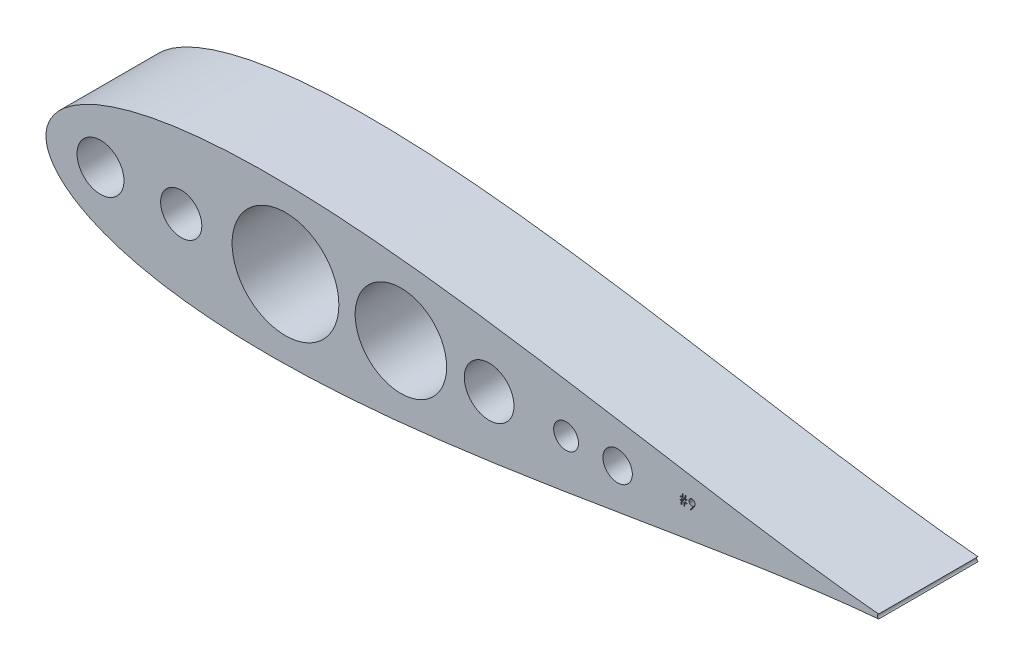
from build123d import *

# Parameters (mm, degrees)
SKETCH2_R           = 12.003328726
SKETCH2_R_2         = 10.541
SKETCH2_R_3         = 27.304154698
SKETCH2_R_4         = 12.7
SKETCH2_R_5         = 7.526838105
SKETCH2_R_6         = 23.387800821
SKETCH2_R_7         = 6.35
BOSS_EXTRUDE1_DEPTH = 50.8


with BuildPart() as part:
    # Sketch2 → Boss-Extrude1 (new body)
    with BuildSketch(Plane.XY):
        with BuildLine():
            ThreePointArc((356.718780851, 1.114246934), (356.028706076, 6.909e-06), (356.718780769, -1.114233167))
            add(Edge.make_bspline(
                [(356.718780851, 1.114246934), (356.033763733, 1.173178101), (354.647215992, 1.292458827), (352.543574548, 1.484422063), (350.391097334, 1.688526485), (348.189855433, 1.905610892), (345.939829836, 2.13545429), (342.180245096, 2.53224762), (336.815818374, 3.133032363), (329.975713328, 3.957551325), (323.033615237, 4.845760717), (313.861506597, 6.078800999), (302.358675653, 7.723739203), (288.633672555, 9.80496392), (274.922061416, 11.972426821), (261.220102315, 14.199869318), (249.806802837, 16.086476937), (240.677387257, 17.603119966), (231.548206374, 19.121176588), (220.136105784, 21.014999661), (206.43726149, 23.261469784), (192.730942806, 25.461990774), (179.01415664, 27.596642338), (160.707707627, 30.327753752), (137.785111444, 33.473978606), (110.200272914, 36.63850744), (87.032056492, 38.598329543), (68.549407972, 39.606704265), (54.551139494, 40.049984194), (40.777416356, 40.122809517), (26.749329002, 39.765508066), (13.011966821, 38.918174763), (-0.797334523, 37.462101359), (-12.083923843, 35.675286751), (-21.141718351, 33.767420445), (-27.946342799, 32.055823242), (-34.595919898, 30.05287379), (-41.12719714, 27.690660012), (-47.426051091, 24.935383745), (-53.537958995, 21.625191978), (-58.335726674, 18.288680808), (-61.800164877, 15.209491695), (-64.191564999, 12.62953081), (-66.221289411, 9.846563829), (-67.842680289, 6.760725103), (-68.898879952, 3.474061054), (-69.273938885, 7e-08), (-68.898880531, -3.47406132), (-67.842729787, -6.760563023), (-66.221390402, -9.846424147), (-64.191776536, -12.62926824), (-61.800292408, -15.209377424), (-58.33586338, -18.288581891), (-53.537959896, -21.625192576), (-47.426050924, -24.935383755), (-41.127353014, -27.690591071), (-34.596083231, -30.052823865), (-27.946507657, -32.055780944), (-21.14171843, -33.767420619), (-12.083923809, -35.675286718), (-0.797502157, -37.462074171), (13.011797104, -38.918163963), (26.74899058, -39.765492278), (40.777247036, -40.122809938), (54.550801678, -40.049989763), (68.549239322, -39.606712891), (87.031888293, -38.598343159), (110.200272912, -36.638507641), (137.785111445, -33.473978545), (160.707707627, -30.327753754), (179.01415664, -27.596642332), (192.730942806, -25.46199077), (206.43726149, -23.261469779), (220.136105784, -21.014999657), (231.548206374, -19.121176584), (240.677387257, -17.603119961), (249.806802838, -16.086476934), (261.220102314, -14.199869298), (274.922061422, -11.972426872), (288.633672533, -9.804963708), (302.358675736, -7.72373997), (313.861339352, -6.07882259), (323.033448412, -4.845786721), (329.975376812, -3.957579056), (336.81565632, -3.1331054), (342.929234171, -2.448200295), (348.139822058, -1.907183748), (352.49338107, -1.483144307), (355.332325035, -1.235291768), (356.718780769, -1.114233167)],
                knots=[0, 0, 0, 0, 0.002325587, 0.004707236, 0.007144984, 0.009638866, 0.012188915, 0.01479516, 0.022426062, 0.030446954, 0.038098675, 0.046098559, 0.061750003, 0.077401464, 0.093052937, 0.108704411, 0.124355886, 0.132181624, 0.140007361, 0.155658837, 0.171310313, 0.18696179, 0.202613269, 0.21826475, 0.249567375, 0.280869705, 0.312171541, 0.328194705, 0.343474536, 0.359539212, 0.374777419, 0.390931321, 0.406079866, 0.4217306, 0.429556884, 0.437383358, 0.445456953, 0.45303644, 0.460863027, 0.46868956, 0.476515268, 0.480563979, 0.4843468, 0.48839404, 0.492178497, 0.496091162, 0.500000012, 0.503908862, 0.507821527, 0.511605415, 0.515653224, 0.519435473, 0.523484757, 0.531310465, 0.539136998, 0.546963585, 0.554542496, 0.562616667, 0.570443141, 0.578269425, 0.593920159, 0.60906813, 0.625222606, 0.640460241, 0.65652549, 0.671804749, 0.687828484, 0.719130321, 0.750432651, 0.781735275, 0.797386757, 0.813038235, 0.828689712, 0.844341188, 0.859992664, 0.867818402, 0.875644139, 0.891295615, 0.906947089, 0.922598561, 0.938250023, 0.953901466, 0.96190078, 0.969553071, 0.977573392, 0.985204866, 0.990360955, 0.995292577, 1, 1, 1, 1], degree=3))
        make_face()
        with Locations((-41.275, 0)):
            Circle(SKETCH2_R, mode=Mode.SUBTRACT)
        Circle(SKETCH2_R_2, mode=Mode.SUBTRACT)
        with Locations((53.337998602, 0)):
            Circle(SKETCH2_R_3, mode=Mode.SUBTRACT)
        with Locations((157.48, 0)):
            Circle(SKETCH2_R_4, mode=Mode.SUBTRACT)
        with Locations((223.213924097, 0)):
            Circle(SKETCH2_R_5, mode=Mode.SUBTRACT)
        with Locations((112.357342011, 0)):
            Circle(SKETCH2_R_6, mode=Mode.SUBTRACT)
        with Locations((196.85, 0)):
            Circle(SKETCH2_R_7, mode=Mode.SUBTRACT)
        Polygon((258.650371578, 1.191086071), (258.650371578, 0.865445046), (257.679554266, 0.865445046), (257.415988566, -0.893016502), (257.022166452, -0.893016502), (257.285732153, 0.865445046), (256.246733754, 0.865445046), (255.983168053, -0.893016502), (255.58934594, -0.893016502), (255.852911641, 0.865445046), (255.003192091, 0.865445046), (255.003192091, 1.191086071), (255.901757792, 1.191086071), (256.077807478, 2.363393759), (255.133448503, 2.363393759), (255.133448503, 2.689034784), (256.126653628, 2.689034784), (256.370884402, 4.31723991), (256.76368888, 4.31723991), (256.519458116, 2.689034784), (257.559474141, 2.689034784), (257.803704915, 4.31723991), (258.196509402, 4.31723991), (257.952278628, 2.689034784), (258.78062799, 2.689034784), (258.78062799, 2.363393759), (257.903432478, 2.363393759), (257.728400427, 1.191086071), align=None, mode=Mode.SUBTRACT)
        Polygon((260.734474141, -1.023272904), (260.370163241, -0.769883489), (261.782631191, 1.294884146), (261.511942091, 1.266390558), (261.24837638, 1.256214272), (261.088608754, 1.263337671), (260.935964528, 1.283690234), (260.78840844, 1.31727196), (260.647975741, 1.365100485), (260.512631191, 1.426158184), (260.38441004, 1.500445046), (260.261277028, 1.588978697), (260.145267415, 1.690741511), (260.039434078, 1.802680621), (259.946829915, 1.920725485), (259.869490166, 2.044876134), (259.805379591, 2.176150171), (259.75653344, 2.312512347), (259.720916452, 2.455997923), (259.699546254, 2.605589272), (259.692422854, 2.761286385), (259.705652028, 2.973970684), (259.744321902, 3.175461071), (259.809450103, 3.366775171), (259.900019015, 3.54689536), (260.015011003, 3.713786385), (260.151373179, 3.862360109), (260.310123179, 3.993634146), (260.490243367, 4.107608498), (260.684610354, 4.199195046), (260.886100741, 4.265340872), (261.094714528, 4.304010747), (261.309434078, 4.31723991), (261.520083116, 4.304010747), (261.722591128, 4.266358498), (261.916958116, 4.202247923), (262.103184078, 4.112696646), (262.276180867, 3.99973991), (262.428825103, 3.867448247), (262.562134402, 3.713786385), (262.676108754, 3.53977196), (262.766677666, 3.353545998), (262.831805867, 3.160196646), (262.870475741, 2.961759146), (262.883704915, 2.756198247), (262.87556388, 2.596430621), (262.85215844, 2.433610109), (262.811453304, 2.265701448), (262.755483754, 2.09473991), (262.720884402, 2.006206259), (262.679161641, 1.913602096), (262.631333116, 1.815909784), (262.577398817, 1.715164596), (262.517358754, 1.608313634), (262.451212927, 1.498409784), (262.377943691, 1.383417797), (262.298568691, 1.264355297), align=None, mode=Mode.SUBTRACT)
    extrude(amount=BOSS_EXTRUDE1_DEPTH)


solid = part.part
